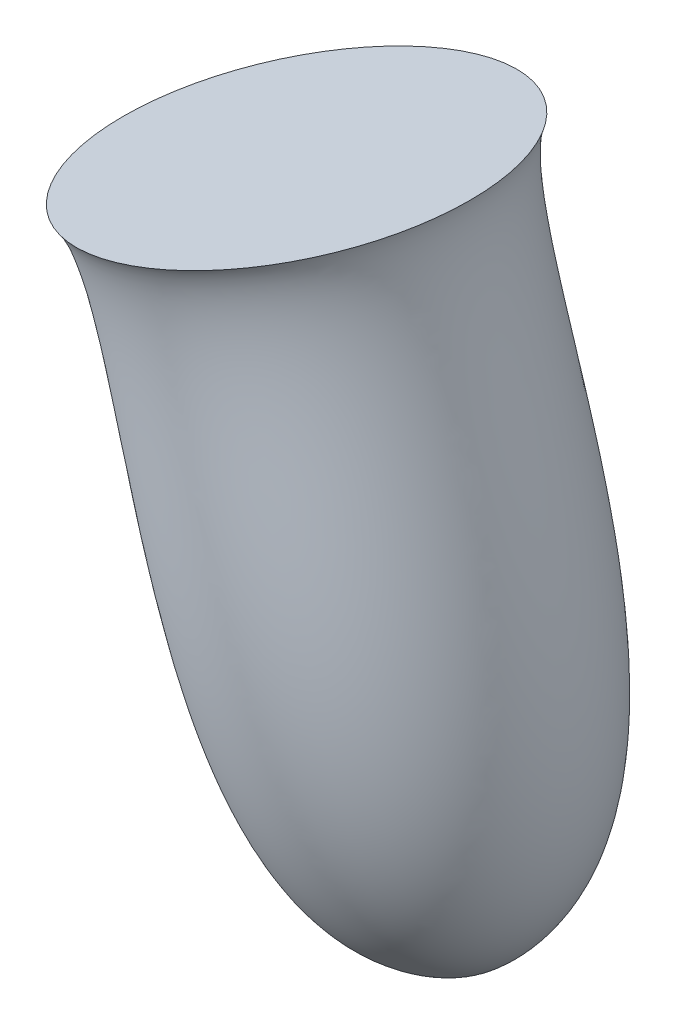
from build123d import *


with BuildPart() as part:
    # Croquis1 → Revolución1 (revolve)
    with BuildSketch(Plane.XY):
        with BuildLine():
            Line((-128.614241961, 34.449551325), (-105.106178469, 41.26759957))
            Line((-105.106178469, 41.26759957), (-80.949536358, -42.022494031))
            add(Edge.make_bspline(
                [(-128.614241961, 34.449551325), (-118.024618976, 25.503282758), (-115.619677289, -44.557023661), (-80.949536358, -42.022494031)],
                knots=[0, 0, 0, 0, 1, 1, 1, 1], degree=3))
        make_face()
    revolve(axis=Axis((-105.106178469, 41.26759957, 0), (0.278551201, -0.960421381, 0)))


solid = part.part
